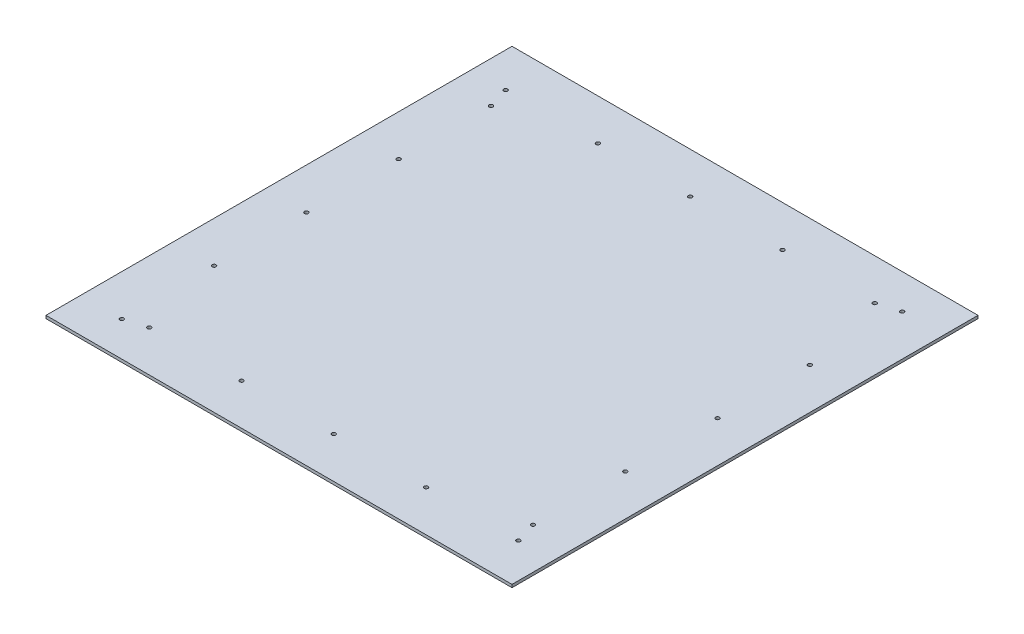
from build123d import *

# Parameters (mm, degrees)
SKETCH1_W           = 510
SKETCH1_H           = 510
BOSS_EXTRUDE1_DEPTH = 3.175
SKETCH3_R           = 2.1
CUT_EXTRUDE1_DEPTH  = 4.175


with BuildPart() as part:
    # Sketch1 → Boss-Extrude1 (new body)
    with BuildSketch(Plane(origin=(0, 0, 0), x_dir=(1, 0, 0), z_dir=(0, 1, 0))):
        Rectangle(SKETCH1_W, SKETCH1_H)
    extrude(amount=BOSS_EXTRUDE1_DEPTH)

    # Sketch3 → Cut-Extrude1 (cut, through all)
    with BuildSketch(Plane.XZ):
        with Locations((217, 210)):
            Circle(SKETCH3_R)
        with Locations((116, 210)):
            Circle(SKETCH3_R)
        with Locations((15, 210)):
            Circle(SKETCH3_R)
        with Locations((-86, 210)):
            Circle(SKETCH3_R)
        with Locations((-187, 210)):
            Circle(SKETCH3_R)
        with Locations((-210, 217)):
            Circle(SKETCH3_R)
        with Locations((-210, 116)):
            Circle(SKETCH3_R)
        with Locations((-210, 15)):
            Circle(SKETCH3_R)
        with Locations((-210, -86)):
            Circle(SKETCH3_R)
        with Locations((-210, -187)):
            Circle(SKETCH3_R)
        with Locations((-217, -210)):
            Circle(SKETCH3_R)
        with Locations((-116, -210)):
            Circle(SKETCH3_R)
        with Locations((-15, -210)):
            Circle(SKETCH3_R)
        with Locations((86, -210)):
            Circle(SKETCH3_R)
        with Locations((187, -210)):
            Circle(SKETCH3_R)
        with Locations((210, -217)):
            Circle(SKETCH3_R)
        with Locations((210, -116)):
            Circle(SKETCH3_R)
        with Locations((210, -15)):
            Circle(SKETCH3_R)
        with Locations((210, 86)):
            Circle(SKETCH3_R)
        with Locations((210, 187)):
            Circle(SKETCH3_R)
    extrude(amount=-CUT_EXTRUDE1_DEPTH, mode=Mode.SUBTRACT)


solid = part.part
